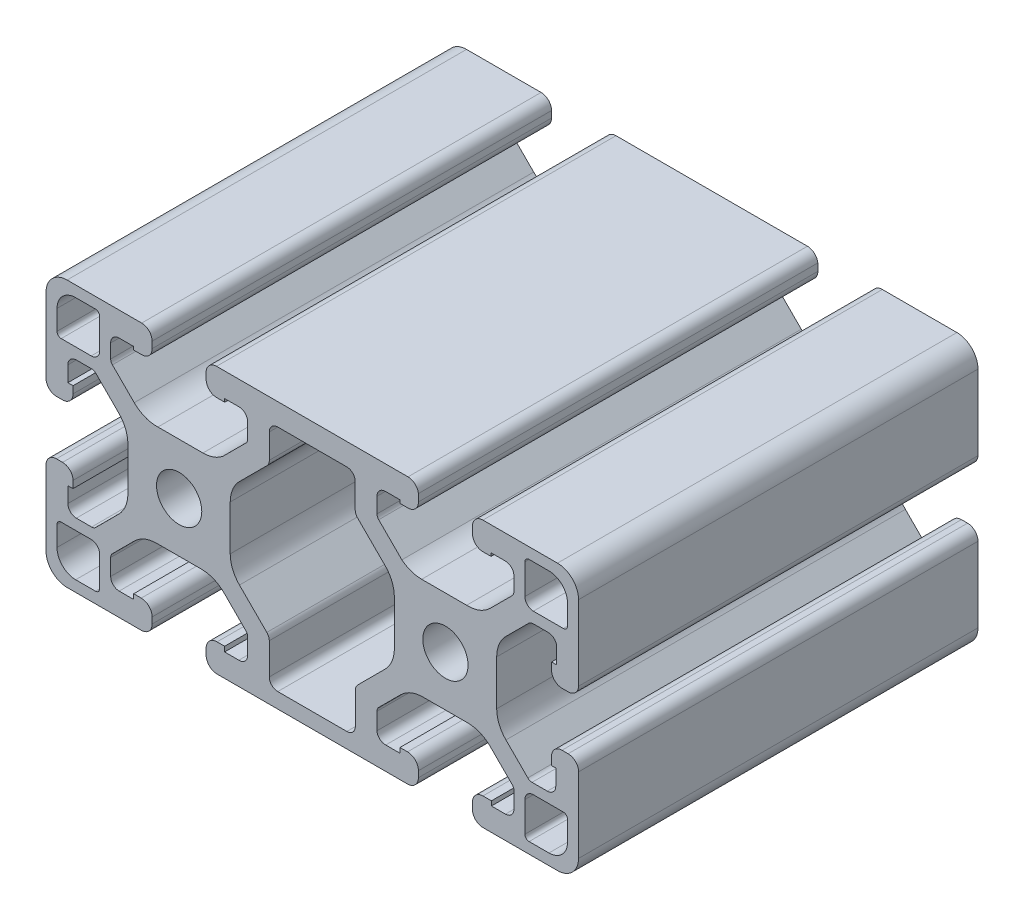
from build123d import *

# Parameters (mm, degrees)
SKETCH1_R      = 3.4
EXTRUDE1_DEPTH = 60


with BuildPart() as part:
    # Sketch1 → Extrude1 (new body)
    with BuildSketch(Plane.XY):
        with BuildLine():
            Line((-34.38, 20), (-5.62, 20))
            ThreePointArc((-5.62, 20), (-4.574261351, 19.60103829), (-4.06, 18.60691806))
            Line((-4.06, 18.60691806), (-4.06, 17.51))
            ThreePointArc((-4.06, 17.51), (-4.519842354, 16.399842354), (-5.63, 15.94))
            Line((-5.63, 15.94), (-6.848295327, 15.94))
            Line((-6.848295327, 15.94), (-6.848295327, 16.411729227))
            Line((-6.848295327, 16.411729227), (-8.956262543, 16.411729227))
            ThreePointArc((-8.956262543, 16.411729227), (-9.89201295, 16.061645977), (-10.285, 15.143088257))
            Line((-10.285, 15.143088257), (-10.285, 12.847645092))
            ThreePointArc((-10.285, 12.847645092), (-10.217146583, 12.506800558), (-10.023932594, 12.217927859))
            Line((-10.023932594, 12.217927859), (-6.541366663, 8.739701268))
            ThreePointArc((-6.541366663, 8.739701268), (-5.14376203, 7.966343661), (-3.568820203, 7.7))
            Line((-3.568820203, 7.7), (3.18718254, 7.7))
            ThreePointArc((3.18718254, 7.7), (5.111909818, 8.02014308), (6.745550907, 9.087046766))
            Line((6.745550907, 9.087046766), (10.024325035, 12.365820894))
            ThreePointArc((10.024325035, 12.365820894), (10.217252784, 12.654557674), (10.285, 12.995145929))
            Line((10.285, 12.995145929), (10.285, 15.086937017))
            ThreePointArc((10.285, 15.086937017), (9.913025612, 15.984962629), (9.015, 16.356937017))
            Line((9.015, 16.356937017), (6.848295327, 16.356937017))
            Line((6.848295327, 16.356937017), (6.848295327, 15.88520779))
            Line((6.848295327, 15.88520779), (5.63, 15.88520779))
            ThreePointArc((5.63, 15.88520779), (4.519842354, 16.345050144), (4.06, 17.45520779))
            Line((4.06, 17.45520779), (4.06, 18.43))
            ThreePointArc((4.06, 18.43), (4.519842354, 19.540157646), (5.63, 20))
            Line((5.63, 20), (14.281820422, 20))
            Line((14.281820422, 20), (16.83, 20))
            ThreePointArc((16.83, 20), (19.071528496, 19.071528496), (20, 16.83))
            Line((20, 16.83), (20, 13))
            Line((20, 13), (20, 5.571883806))
            ThreePointArc((20, 5.571883806), (19.520492841, 4.499481643), (18.431075989, 4.059999631))
            Line((18.431075989, 4.059999631), (17.51, 4.059999631))
            ThreePointArc((17.51, 4.059999631), (16.399842354, 4.519841985), (15.94, 5.629999631))
            Line((15.94, 5.629999631), (15.94, 6.696409732))
            Line((15.94, 6.696409732), (16.715022223, 6.696409732))
            Line((16.715022223, 6.696409732), (16.715022223, 9.02))
            ThreePointArc((16.715022223, 9.02), (16.343047835, 9.918025612), (15.445022223, 10.29))
            Line((15.445022223, 10.29), (13.15011805, 10.29))
            ThreePointArc((13.15011805, 10.29), (12.809529795, 10.222252784), (12.520793015, 10.029325035))
            Line((12.520793015, 10.029325035), (9.091242789, 6.59977481))
            ThreePointArc((9.091242789, 6.59977481), (8.061572221, 5.058763903), (7.7, 3.241017599))
            Line((7.7, 3.241017599), (7.7, -3.514985144))
            ThreePointArc((7.7, -3.514985144), (8.061005845, -5.331363493), (9.089149602, -6.871647862))
            Line((9.089149602, -6.871647862), (12.377834665, -10.164435797))
            ThreePointArc((12.377834665, -10.164435797), (12.666707364, -10.357649787), (13.007551897, -10.425503204))
            Line((13.007551897, -10.425503204), (15.30245607, -10.425503204))
            ThreePointArc((15.30245607, -10.425503204), (16.200481682, -10.053528816), (16.57245607, -9.155503204))
            Line((16.57245607, -9.155503204), (16.57245607, -6.779901474))
            Line((16.57245607, -6.779901474), (15.94, -6.779901474))
            Line((15.94, -6.779901474), (15.94, -5.569550674))
            ThreePointArc((15.94, -5.569550674), (16.399842354, -4.459393028), (17.51, -3.999550674))
            Line((17.51, -3.999550674), (18.43, -3.999550674))
            ThreePointArc((18.43, -3.999550674), (19.540157646, -4.459393028), (20, -5.569550674))
            Line((20, -5.569550674), (20, -16.83))
            ThreePointArc((20, -16.83), (19.071528496, -19.071528496), (16.83, -20))
            Line((16.83, -20), (14.322274694, -20))
            Line((14.322274694, -20), (5.694366927, -20))
            ThreePointArc((5.694366927, -20), (4.542837301, -19.564006433), (4.059999445, -18.431320037))
            Line((4.059999445, -18.431320037), (4.059999445, -17.45520779))
            ThreePointArc((4.059999445, -17.45520779), (4.519841799, -16.345050144), (5.629999445, -15.88520779))
            Line((5.629999445, -15.88520779), (6.907032762, -15.88520779))
            Line((6.907032762, -15.88520779), (6.907032762, -16.558380889))
            Line((6.907032762, -16.558380889), (9.015, -16.558380889))
            ThreePointArc((9.015, -16.558380889), (9.913025612, -16.186406501), (10.285, -15.288380889))
            Line((10.285, -15.288380889), (10.285, -12.829086847))
            ThreePointArc((10.285, -12.829086847), (10.217252784, -12.488498592), (10.024325035, -12.199761812))
            Line((10.024325035, -12.199761812), (6.739188515, -8.914625291))
            ThreePointArc((6.739188515, -8.914625291), (5.199545386, -7.885521524), (3.383392441, -7.523383425))
            Line((3.383392441, -7.523383425), (-3.380431304, -7.523383425))
            ThreePointArc((-3.380431304, -7.523383425), (-5.198177608, -7.884955645), (-6.739188515, -8.914626214))
            Line((-6.739188515, -8.914626214), (-10.024325035, -12.199762735))
            ThreePointArc((-10.024325035, -12.199762735), (-10.217252784, -12.488499515), (-10.285, -12.82908777))
            Line((-10.285, -12.82908777), (-10.285, -15.368632999))
            ThreePointArc((-10.285, -15.368632999), (-9.869779979, -16.230781197), (-8.970677639, -16.558381812))
            Line((-8.970677639, -16.558381812), (-6.828250761, -16.558381812))
            Line((-6.828250761, -16.558381812), (-6.828250761, -15.813027771))
            Line((-6.828250761, -15.813027771), (-5.694367402, -15.813027771))
            ThreePointArc((-5.694367402, -15.813027771), (-4.538695129, -16.2917229), (-4.06, -17.447395173))
            Line((-4.06, -17.447395173), (-4.06, -18.365632122))
            ThreePointArc((-4.06, -18.365632122), (-4.538694961, -19.521304703), (-5.694367402, -20))
            Line((-5.694367402, -20), (-13.060449326, -20))
            Line((-13.060449326, -20), (-26.939550674, -20))
            Line((-26.939550674, -20), (-34.305633073, -20))
            ThreePointArc((-34.305633073, -20), (-35.461305039, -19.521304703), (-35.94, -18.365632598))
            Line((-35.94, -18.365632598), (-35.94, -17.447395173))
            ThreePointArc((-35.94, -17.447395173), (-35.461304871, -16.2917229), (-34.305632598, -15.813027771))
            Line((-34.305632598, -15.813027771), (-33.171749239, -15.813027771))
            Line((-33.171749239, -15.813027771), (-33.171749239, -16.558380889))
            Line((-33.171749239, -16.558380889), (-31.029322361, -16.558380889))
            ThreePointArc((-31.029322361, -16.558380889), (-30.130220021, -16.230780274), (-29.715, -15.368632076))
            Line((-29.715, -15.368632076), (-29.715, -12.829086847))
            ThreePointArc((-29.715, -12.829086847), (-29.782747216, -12.488498592), (-29.975674965, -12.199761812))
            Line((-29.975674965, -12.199761812), (-33.260811485, -8.914625291))
            ThreePointArc((-33.260811485, -8.914625291), (-34.801822392, -7.884954722), (-36.619568696, -7.523382502))
            Line((-36.619568696, -7.523382502), (-43.380431304, -7.523382502))
            ThreePointArc((-43.380431304, -7.523382502), (-45.198177608, -7.884954722), (-46.739188515, -8.914625291))
            Line((-46.739188515, -8.914625291), (-50.024325035, -12.199761812))
            ThreePointArc((-50.024325035, -12.199761812), (-50.217252784, -12.488498592), (-50.285, -12.829086847))
            Line((-50.285, -12.829086847), (-50.285, -15.288380889))
            ThreePointArc((-50.285, -15.288380889), (-49.913025612, -16.186406501), (-49.015, -16.558380889))
            Line((-49.015, -16.558380889), (-46.828250761, -16.558380889))
            Line((-46.828250761, -16.558380889), (-46.828250761, -15.813027771))
            Line((-46.828250761, -15.813027771), (-45.694367402, -15.813027771))
            ThreePointArc((-45.694367402, -15.813027771), (-44.538695129, -16.2917229), (-44.06, -17.447395173))
            Line((-44.06, -17.447395173), (-44.06, -18.365632598))
            ThreePointArc((-44.06, -18.365632598), (-44.538694961, -19.521304703), (-45.694366927, -20))
            Line((-45.694366927, -20), (-56.83, -20))
            ThreePointArc((-56.83, -20), (-59.071528496, -19.071528496), (-60, -16.83))
            Line((-60, -16.83), (-60, -5.571883806))
            ThreePointArc((-60, -5.571883806), (-59.520492841, -4.499481643), (-58.431075989, -4.059999631))
            Line((-58.431075989, -4.059999631), (-57.51, -4.06))
            ThreePointArc((-57.51, -4.06), (-56.399842354, -4.519842354), (-55.94, -5.63))
            Line((-55.94, -5.63), (-55.94, -6.696410101))
            Line((-55.94, -6.696410101), (-56.715022223, -6.696410101))
            Line((-56.715022223, -6.696410101), (-56.715022223, -9.02))
            ThreePointArc((-56.715022223, -9.02), (-56.343047835, -9.918025612), (-55.445022223, -10.29))
            Line((-55.445022223, -10.29), (-53.15011805, -10.29))
            ThreePointArc((-53.15011805, -10.29), (-52.809529795, -10.222252784), (-52.520793015, -10.029325035))
            Line((-52.520793015, -10.029325035), (-49.091242789, -6.59977481))
            ThreePointArc((-49.091242789, -6.59977481), (-48.061572221, -5.058763903), (-47.7, -3.241017599))
            Line((-47.7, -3.241017599), (-47.7, 3.241017599))
            ThreePointArc((-47.7, 3.241017599), (-48.061572221, 5.058763903), (-49.091242789, 6.59977481))
            Line((-49.091242789, 6.59977481), (-52.520793015, 10.029325035))
            ThreePointArc((-52.520793015, 10.029325035), (-52.809529795, 10.222252784), (-53.15011805, 10.29))
            Line((-53.15011805, 10.29), (-55.445022223, 10.29))
            ThreePointArc((-55.445022223, 10.29), (-56.343047835, 9.918025612), (-56.715022223, 9.02))
            Line((-56.715022223, 9.02), (-56.715022223, 6.696410101))
            Line((-56.715022223, 6.696410101), (-55.94, 6.696410101))
            Line((-55.94, 6.696410101), (-55.94, 5.63))
            ThreePointArc((-55.94, 5.63), (-56.399842354, 4.519842354), (-57.51, 4.06))
            Line((-57.51, 4.06), (-58.431075989, 4.059999631))
            ThreePointArc((-58.431075989, 4.059999631), (-59.520492841, 4.499481643), (-60, 5.571883806))
            Line((-60, 5.571883806), (-60, 13))
            Line((-60, 13), (-60, 16.83))
            ThreePointArc((-60, 16.83), (-59.071528496, 19.071528496), (-56.83, 20))
            Line((-56.83, 20), (-45.63, 20))
            ThreePointArc((-45.63, 20), (-44.519842354, 19.540157646), (-44.06, 18.43))
            Line((-44.06, 18.43), (-44.06, 17.45520779))
            ThreePointArc((-44.06, 17.45520779), (-44.519842354, 16.345050144), (-45.63, 15.88520779))
            Line((-45.63, 15.88520779), (-46.848295327, 15.88520779))
            Line((-46.848295327, 15.88520779), (-46.848295327, 16.356937017))
            Line((-46.848295327, 16.356937017), (-49.015, 16.356937017))
            ThreePointArc((-49.015, 16.356937017), (-49.913025612, 15.984962629), (-50.285, 15.086937017))
            Line((-50.285, 15.086937017), (-50.285, 12.995145929))
            ThreePointArc((-50.285, 12.995145929), (-50.217252784, 12.654557674), (-50.024325035, 12.365820894))
            Line((-50.024325035, 12.365820894), (-46.745550907, 9.087046766))
            ThreePointArc((-46.745550907, 9.087046766), (-45.111909818, 8.02014308), (-43.18718254, 7.7))
            Line((-43.18718254, 7.7), (-36.42447528, 7.7))
            ThreePointArc((-36.42447528, 7.7), (-34.853074074, 7.967456275), (-33.458633337, 8.739706))
            Line((-33.458633337, 8.739706), (-29.976067406, 12.217932591))
            ThreePointArc((-29.976067406, 12.217932591), (-29.782853417, 12.50680529), (-29.715, 12.847649823))
            Line((-29.715, 12.847649823), (-29.715, 15.143088257))
            ThreePointArc((-29.715, 15.143088257), (-30.107987042, 16.061645969), (-31.043737435, 16.411729227))
            Line((-31.043737435, 16.411729227), (-33.151704673, 16.411729227))
            Line((-33.151704673, 16.411729227), (-33.151704673, 15.94))
            Line((-33.151704673, 15.94), (-34.37, 15.94))
            ThreePointArc((-34.37, 15.94), (-35.480157646, 16.399842354), (-35.94, 17.51))
            Line((-35.94, 17.51), (-35.94, 18.60691806))
            ThreePointArc((-35.94, 18.60691806), (-35.425738649, 19.60103829), (-34.38, 20))
        make_face()
        with Locations((-40, 0)):
            Circle(SKETCH1_R, mode=Mode.SUBTRACT)
        Circle(SKETCH1_R, mode=Mode.SUBTRACT)
        with BuildLine():
            Line((-30.939717555, -6.735226492), (-26.832379884, -10.842564163))
            ThreePointArc((-26.832379884, -10.842564163), (-26.55707849, -11.254581816), (-26.460405496, -11.740589775))
            Line((-26.460405496, -11.740589775), (-26.460405496, -16.447436081))
            ThreePointArc((-26.460405496, -16.447436081), (-26.088431108, -17.345461693), (-25.190405496, -17.717436081))
            Line((-25.190405496, -17.717436081), (-14.809594504, -17.717436081))
            ThreePointArc((-14.809594504, -17.717436081), (-13.911568892, -17.345461693), (-13.539594504, -16.447436081))
            Line((-13.539594504, -16.447436081), (-13.539594504, -11.740589775))
            ThreePointArc((-13.539594504, -11.740589775), (-13.442921131, -11.254581958), (-13.167619463, -10.842564566))
            Line((-13.167619463, -10.842564566), (-9.062375632, -6.737320735))
            ThreePointArc((-9.062375632, -6.737320735), (-8.032138688, -5.194941873), (-7.671133766, -3.375602388))
            Line((-7.671133766, -3.375602388), (-7.675346726, 3.3824627))
            ThreePointArc((-7.675346726, 3.3824627), (-8.038052054, 5.199983248), (-9.068683085, 6.740351962))
            Line((-9.068683085, 6.740351962), (-13.17858046, 10.845128331))
            ThreePointArc((-13.17858046, 10.845128331), (-13.453881854, 11.257145984), (-13.550554848, 11.743153943))
            Line((-13.550554848, 11.743153943), (-13.550554848, 15.430000252))
            ThreePointArc((-13.550554848, 15.430000252), (-13.922527865, 16.328024493), (-14.820550972, 16.700000252))
            Line((-14.820550972, 16.700000252), (-20.000001006, 16.696771398))
            Line((-20.000001006, 16.696771398), (-25.178653438, 16.699999756))
            ThreePointArc((-25.178653438, 16.699999756), (-26.077190808, 16.328305483), (-26.449445152, 15.43))
            Line((-26.449445152, 15.43), (-26.449445152, 11.743153694))
            ThreePointArc((-26.449445152, 11.743153694), (-26.546118146, 11.257145735), (-26.82141954, 10.845128082))
            Line((-26.82141954, 10.845128082), (-30.931316915, 6.740351712))
            ThreePointArc((-30.931316915, 6.740351712), (-31.961947946, 5.199982999), (-32.324653274, 3.382462451))
            Line((-32.324653274, 3.382462451), (-32.328866234, -3.375602637))
            ThreePointArc((-32.328866234, -3.375602637), (-31.968427261, -5.193573991), (-30.939717555, -6.735226492))
        make_face(mode=Mode.SUBTRACT)
        with BuildLine():
            Line((-57.72, 11.94), (-53.21, 11.94))
            ThreePointArc((-53.21, 11.94), (-52.308743898, 12.310198515), (-51.935, 13.209990157))
            Line((-51.935, 13.209990157), (-51.935, 17.72))
            ThreePointArc((-51.935, 17.72), (-52.119522728, 18.165477272), (-52.565, 18.35))
            Line((-52.565, 18.35), (-55.545, 18.35))
            ThreePointArc((-55.545, 18.35), (-57.524898987, 17.529898987), (-58.345, 15.55))
            Line((-58.345, 15.55), (-58.345, 12.569980158))
            ThreePointArc((-58.345, 12.569980158), (-58.162241545, 12.126274175), (-57.72, 11.94))
        make_face(mode=Mode.SUBTRACT)
        with BuildLine():
            Line((-51.935, -17.72), (-51.935, -13.209990157))
            ThreePointArc((-51.935, -13.209990157), (-52.308743898, -12.310198515), (-53.21, -11.94))
            Line((-53.21, -11.94), (-57.72, -11.94))
            ThreePointArc((-57.72, -11.94), (-58.162241545, -12.126274175), (-58.345, -12.569980158))
            Line((-58.345, -12.569980158), (-58.345, -15.55))
            ThreePointArc((-58.345, -15.55), (-57.524898987, -17.529898987), (-55.545, -18.35))
            Line((-55.545, -18.35), (-52.565, -18.35))
            ThreePointArc((-52.565, -18.35), (-52.119522728, -18.165477272), (-51.935, -17.72))
        make_face(mode=Mode.SUBTRACT)
        with BuildLine():
            Line((18.345, -15.55), (18.345, -12.57))
            ThreePointArc((18.345, -12.57), (18.162248533, -12.126281217), (17.72, -11.94))
            Line((17.72, -11.94), (13.21, -11.94))
            ThreePointArc((13.21, -11.94), (12.308743898, -12.310198515), (11.935, -13.209990157))
            Line((11.935, -13.209990157), (11.935, -17.72))
            ThreePointArc((11.935, -17.72), (12.119522728, -18.165477272), (12.565, -18.35))
            Line((12.565, -18.35), (15.545, -18.35))
            ThreePointArc((15.545, -18.35), (17.524898987, -17.529898987), (18.345, -15.55))
        make_face(mode=Mode.SUBTRACT)
        with BuildLine():
            Line((18.345, 15.55), (18.345, 12.57))
            ThreePointArc((18.345, 12.57), (18.162248533, 12.126281217), (17.72, 11.94))
            Line((17.72, 11.94), (13.21, 11.94))
            ThreePointArc((13.21, 11.94), (12.308743898, 12.310198515), (11.935, 13.209990157))
            Line((11.935, 13.209990157), (11.935, 17.72))
            ThreePointArc((11.935, 17.72), (12.119522728, 18.165477272), (12.565, 18.35))
            Line((12.565, 18.35), (15.545, 18.35))
            ThreePointArc((15.545, 18.35), (17.524898987, 17.529898987), (18.345, 15.55))
        make_face(mode=Mode.SUBTRACT)
    extrude(amount=-EXTRUDE1_DEPTH)


solid = part.part
